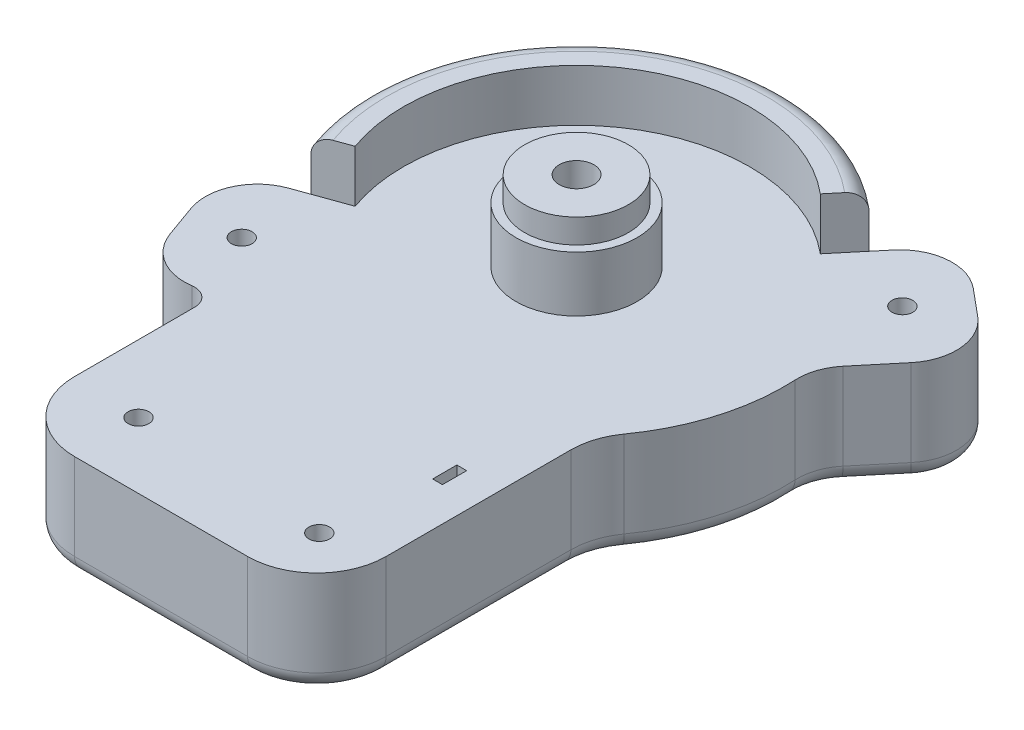
from build123d import *

# Parameters (mm, degrees)
BOSS_EXTRUDE1_DEPTH = 30
SKETCH3_R           = 6
CUT_EXTRUDE2_DEPTH  = 10
CUT_EXTRUDE3_REACH  = 22
SKETCH4_R           = 3
SKETCH5_R           = 17.5
BOSS_EXTRUDE2_DEPTH = 16
SKETCH6_R           = 15
BOSS_EXTRUDE3_DEPTH = 7
BOSS_EXTRUDE4_DEPTH = 15
FILLET1_R           = 5
CUT_EXTRUDE4_REACH  = 55
SKETCH8_R           = 5
CUT_EXTRUDE5_REACH  = 32
SKETCH9_W           = 2.838035454
SKETCH9_H           = 7.000000767
CUT_EXTRUDE6_DEPTH  = 10


with BuildPart() as part:
    # Sketch1 → Boss-Extrude1 (new body)
    with BuildSketch(Plane(origin=(0, 0, 0), x_dir=(-1, 0, 0), z_dir=(0, -1, 0))):
        with BuildLine():
            Line((-155.978842812, -669.571630145), (-160.685424707, -671.259257732))
            ThreePointArc((-160.685424707, -671.259257732), (-169.1867086, -678.974834226), (-169.742287629, -690.441886175))
            Line((-169.742287629, -690.441886175), (-166.367032456, -699.855049964))
            ThreePointArc((-166.367032456, -699.855049964), (-160.015233889, -707.624119417), (-150.186716753, -709.649961495))
            ThreePointArc((-150.186716753, -709.649961495), (-146.216133795, -710.831997076), (-144.49986008, -714.602559592))
            Line((-144.49986008, -714.602559592), (-144.49986008, -749.320099104))
            ThreePointArc((-144.49986008, -749.320099104), (-138.641995704, -763.462234727), (-124.49986008, -769.320099104))
            Line((-124.49986008, -769.320099104), (-74.49986008, -769.320099104))
            ThreePointArc((-74.49986008, -769.320099104), (-60.357724456, -763.462234727), (-54.49986008, -749.320099104))
            Line((-54.49986008, -749.320099104), (-54.49986008, -695.956994369))
            ThreePointArc((-54.49986008, -695.956994369), (-53.539292845, -689.833270012), (-50.74986008, -684.297770553))
            ThreePointArc((-50.74986008, -684.297770553), (-41.916134266, -666.175796103), (-39.583621808, -646.150810326))
            ThreePointArc((-39.583621808, -646.150810326), (-38.838622962, -640.626520742), (-36.127881434, -635.755722136))
            Line((-36.127881434, -635.755722136), (-27.159022918, -624.993091916))
            ThreePointArc((-27.159022918, -624.993091916), (-23.743944015, -614.032289731), (-29.079576117, -603.867006728))
            Line((-29.079576117, -603.867006728), (-36.761788913, -597.465162731))
            ThreePointArc((-36.761788913, -597.465162731), (-47.722591099, -594.050083828), (-57.887874102, -599.38571593))
            Line((-57.887874102, -599.38571593), (-61.0887961, -603.226822328))
            ThreePointArc((-61.0887961, -603.226822328), (-133.880389498, -600.14714722), (-155.978842812, -669.571630145))
        make_face()
    extrude(amount=BOSS_EXTRUDE1_DEPTH)

    # Sketch3 → Cut-Extrude2 (cut)
    with BuildSketch(Plane.XZ.offset(30)):
        with Locations((42.52344851, 612.189403923)):
            Circle(SKETCH3_R)
        with Locations((155.092642393, 690.430908662)):
            Circle(SKETCH3_R)
        with Locations((124.976355339, 750.357765174)):
            Circle(SKETCH3_R)
        with Locations((70.026025263, 753.095100306)):
            Circle(SKETCH3_R)
    extrude(amount=-CUT_EXTRUDE2_DEPTH, mode=Mode.SUBTRACT)

    # Sketch4 → Cut-Extrude3 (cut, up to next)
    with BuildSketch(Plane.XZ.offset(20), mode=Mode.PRIVATE) as cut_extrude3_sk1:
        with Locations((42.52344851, 612.189403923)):
            Circle(SKETCH4_R)
    cut_extrude3_tool1 = extrude(cut_extrude3_sk1.sketch, amount=-CUT_EXTRUDE3_REACH, mode=Mode.PRIVATE) & part.part
    add(cut_extrude3_tool1.solids().sort_by_distance((42.523449, -20, 612.189404))[0], mode=Mode.SUBTRACT)
    # Sketch4 → Cut-Extrude3 (cut, up to next)
    with BuildSketch(Plane.XZ.offset(20), mode=Mode.PRIVATE) as cut_extrude3_sk2:
        with Locations((155.092642393, 690.430908662)):
            Circle(SKETCH4_R)
    cut_extrude3_tool2 = extrude(cut_extrude3_sk2.sketch, amount=-CUT_EXTRUDE3_REACH, mode=Mode.PRIVATE) & part.part
    add(cut_extrude3_tool2.solids().sort_by_distance((155.092642, -20, 690.430909))[0], mode=Mode.SUBTRACT)
    # Sketch4 → Cut-Extrude3 (cut, up to next)
    with BuildSketch(Plane.XZ.offset(20), mode=Mode.PRIVATE) as cut_extrude3_sk3:
        with Locations((124.976355339, 750.357765174)):
            Circle(SKETCH4_R)
    cut_extrude3_tool3 = extrude(cut_extrude3_sk3.sketch, amount=-CUT_EXTRUDE3_REACH, mode=Mode.PRIVATE) & part.part
    add(cut_extrude3_tool3.solids().sort_by_distance((124.976355, -20, 750.357765))[0], mode=Mode.SUBTRACT)
    # Sketch4 → Cut-Extrude3 (cut, up to next)
    with BuildSketch(Plane.XZ.offset(20), mode=Mode.PRIVATE) as cut_extrude3_sk4:
        with Locations((70.026025263, 753.095100306)):
            Circle(SKETCH4_R)
    cut_extrude3_tool4 = extrude(cut_extrude3_sk4.sketch, amount=-CUT_EXTRUDE3_REACH, mode=Mode.PRIVATE) & part.part
    add(cut_extrude3_tool4.solids().sort_by_distance((70.026025, -20, 753.0951))[0], mode=Mode.SUBTRACT)

    # Sketch5 → Boss-Extrude2 (add)
    with BuildSketch(Plane(origin=(0, 0, 0), x_dir=(1, 0, 0), z_dir=(0, 1, 0))):
        with Locations((99.49986008, -649.320099104)):
            Circle(SKETCH5_R)
    extrude(amount=BOSS_EXTRUDE2_DEPTH)

    # Sketch6 → Boss-Extrude3 (add)
    with BuildSketch(Plane(origin=(0, 16, 0), x_dir=(1, 0, 0), z_dir=(0, 1, 0))):
        with Locations((99.49986008, -649.320099104)):
            Circle(SKETCH6_R)
    extrude(amount=BOSS_EXTRUDE3_DEPTH)

    # Sketch7 → Boss-Extrude4 (add)
    with BuildSketch(Plane(origin=(0, 0, 0), x_dir=(1, 0, 0), z_dir=(0, 1, 0))):
        with BuildLine():
            Line((155.978842812, -669.571630145), (146.565591992, -666.196355925))
            ThreePointArc((146.565591992, -666.196355925), (128.150229883, -608.342615172), (67.490568023, -610.908994684))
            Line((67.490568023, -610.908994684), (61.0887961, -603.226822328))
            ThreePointArc((61.0887961, -603.226822328), (133.880389498, -600.14714722), (155.978842812, -669.571630145))
        make_face()
    extrude(amount=BOSS_EXTRUDE4_DEPTH)

    # Fillet1
    fillet1_edges = [part.edges().sort_by_distance(p)[0] for p in [
        (133.880389498, 15, 600.14714722),
        (23.743944015, -30, 614.032289731),
        (32.920682515, -30, 600.666084729),
        (47.722591099, -30, 594.050083828),
        (59.488335101, -30, 601.306269129),
        (133.880389498, -30, 600.14714722),
        (158.332133759, -30, 670.415443939),
        (169.1867086, -30, 678.974834226),
        (168.054660043, -30, 695.14846807),
        (160.015233889, -30, 707.624119417),
        (146.216133795, -30, 710.831997076),
        (38.838622962, -30, 640.626520742),
        (144.49986008, -30, 731.961329348),
        (138.641995704, -30, 763.462234727),
        (99.49986008, -30, 769.320099104),
        (60.357724456, -30, 763.462234727),
        (54.49986008, -30, 722.638546736),
        (53.539292845, -30, 689.833270012),
        (41.916134266, -30, 666.175796103),
        (31.643452176, -30, 630.374407026),
    ]]
    fillet(fillet1_edges, radius=FILLET1_R)


with BuildPart() as body_2:
    # Mirror1: mirrored copy
    add(part.part.mirror(Plane(origin=(0, 0, 0), x_dir=(0, 0, 1), z_dir=(1, 0, 0))))

    # Sketch8 → Cut-Extrude4 (cut, up to next)
    with BuildSketch(Plane(origin=(0, 23, 0), x_dir=(1, 0, 0), z_dir=(0, 1, 0)), mode=Mode.PRIVATE) as cut_extrude4_sk1:
        with Locations((-99.49986008, -649.320099104)):
            Circle(SKETCH8_R)
    cut_extrude4_tool1 = extrude(cut_extrude4_sk1.sketch, amount=-CUT_EXTRUDE4_REACH, mode=Mode.PRIVATE) & body_2.part
    add(cut_extrude4_tool1.solids().sort_by_distance((-99.49986, 23, 649.320099))[0], mode=Mode.SUBTRACT)

    # Sketch9 → Cut-Extrude5 (cut, up to next)
    with BuildSketch(Plane(origin=(0, 0, 0), x_dir=(1, 0, 0), z_dir=(0, 1, 0)), mode=Mode.PRIVATE) as cut_extrude5_sk1:
        with Locations((-65.749484781, -719.720058193)):
            Rectangle(SKETCH9_W, SKETCH9_H)
    cut_extrude5_tool1 = extrude(cut_extrude5_sk1.sketch, amount=-CUT_EXTRUDE5_REACH, mode=Mode.PRIVATE) & body_2.part
    add(cut_extrude5_tool1.solids().sort_by_distance((-65.749485, 0, 719.720058))[0], mode=Mode.SUBTRACT)

    # Sketch10 → Cut-Extrude6 (cut)
    with BuildSketch(Plane.XZ.offset(30)):
        with BuildLine():
            Line((-67.168502508, 716.220057809), (-87.168574927, 716.220057809))
            ThreePointArc((-87.168574927, 716.220057809), (-92.788411024, 714.505734169), (-95.54986008, 709.319612071))
            Line((-95.54986008, 709.319612071), (-95.54986008, 649.320099104))
            Line((-95.54986008, 649.320099104), (-103.44986008, 649.320099104))
            Line((-103.44986008, 649.320099104), (-103.44986008, 709.320099104))
            ThreePointArc((-103.44986008, 709.320099104), (-98.187987541, 719.642036576), (-87.168574927, 723.220058576))
            Line((-87.168574927, 723.220058576), (-67.168502508, 723.220058576))
            Line((-67.168502508, 723.220058576), (-67.168502508, 716.220057809))
        make_face()
    extrude(amount=-CUT_EXTRUDE6_DEPTH, mode=Mode.SUBTRACT)


solid = body_2.part
